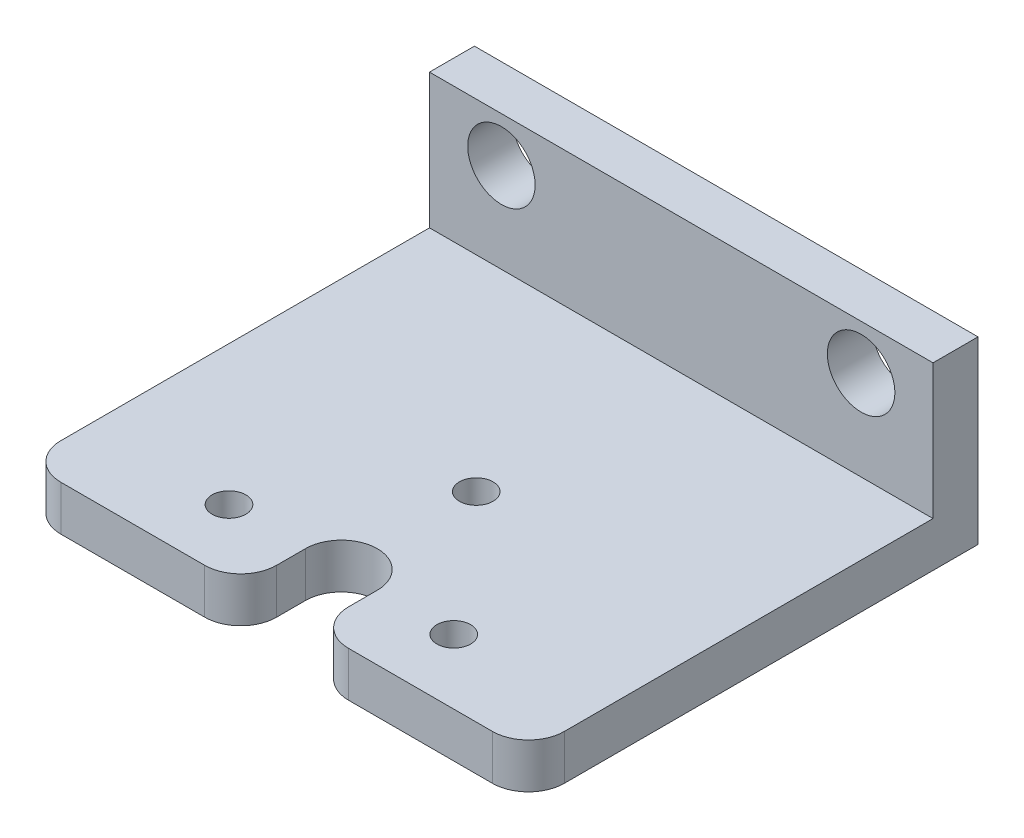
from build123d import *

# Parameters (mm, degrees)
SKETCH1_W           = 35.56
SKETCH1_H           = 12.7
SKETCH1_R           = 2.38125
BOSS_EXTRUDE1_DEPTH = 3.175
SKETCH7_W           = 35.56
SKETCH7_H           = 3.175
BOSS_EXTRUDE3_DEPTH = 28.575
SKETCH11_R          = 1.190625
CUT_EXTRUDE1_DEPTH  = 13.7
FILLET1_R           = 2.54
CHAMFER2_SIZE       = 1.27


with BuildPart() as part:
    # Sketch1 → Boss-Extrude1 (new body)
    with BuildSketch(Plane.XY):
        Rectangle(SKETCH1_W, SKETCH1_H)
        with Locations((-12.7, 3.175)):
            Circle(SKETCH1_R, mode=Mode.SUBTRACT)
        with Locations((12.7, 3.175)):
            Circle(SKETCH1_R, mode=Mode.SUBTRACT)
    extrude(amount=BOSS_EXTRUDE1_DEPTH)

    # Sketch7 → Boss-Extrude3 (add)
    with BuildSketch(Plane.XY.offset(3.175)):
        with Locations((0, -4.7625)):
            Rectangle(SKETCH7_W, SKETCH7_H)
    extrude(amount=BOSS_EXTRUDE3_DEPTH)

    # Sketch11 → Cut-Extrude1 (cut, through all)
    with BuildSketch(Plane.XZ.offset(6.35)):
        with Locations((-7.9375, 27.178)):
            Circle(SKETCH11_R)
        with Locations((7.9375, 27.178)):
            Circle(SKETCH11_R)
        with Locations((0, 17.653)):
            Circle(SKETCH11_R)
        with BuildLine():
            Line((-2.54, 48.261780908), (2.54, 48.261780908))
            Line((2.54, 48.261780908), (2.54, 27.178))
            ThreePointArc((2.54, 27.178), (0, 24.638), (-2.54, 27.178))
            Line((-2.54, 27.178), (-2.54, 48.261780908))
        make_face()
    extrude(amount=-CUT_EXTRUDE1_DEPTH, mode=Mode.SUBTRACT)

    # Fillet1
    fillet1_edges = [part.edges().sort_by_distance(p)[0] for p in [
        (-17.78, -4.7625, 31.75),
        (17.78, -4.7625, 31.75),
        (2.54, -4.7625, 31.75),
        (-2.54, -4.7625, 31.75),
    ]]
    fillet(fillet1_edges, radius=FILLET1_R)

    # Chamfer2
    chamfer2_edges = [part.edges().sort_by_distance(p)[0] for p in [
        (-9.128125, -6.35, 27.178),
        (6.746875, -6.35, 27.178),
        (-1.190625, -6.35, 17.653),
    ]]
    chamfer(chamfer2_edges, length=CHAMFER2_SIZE)


solid = part.part
